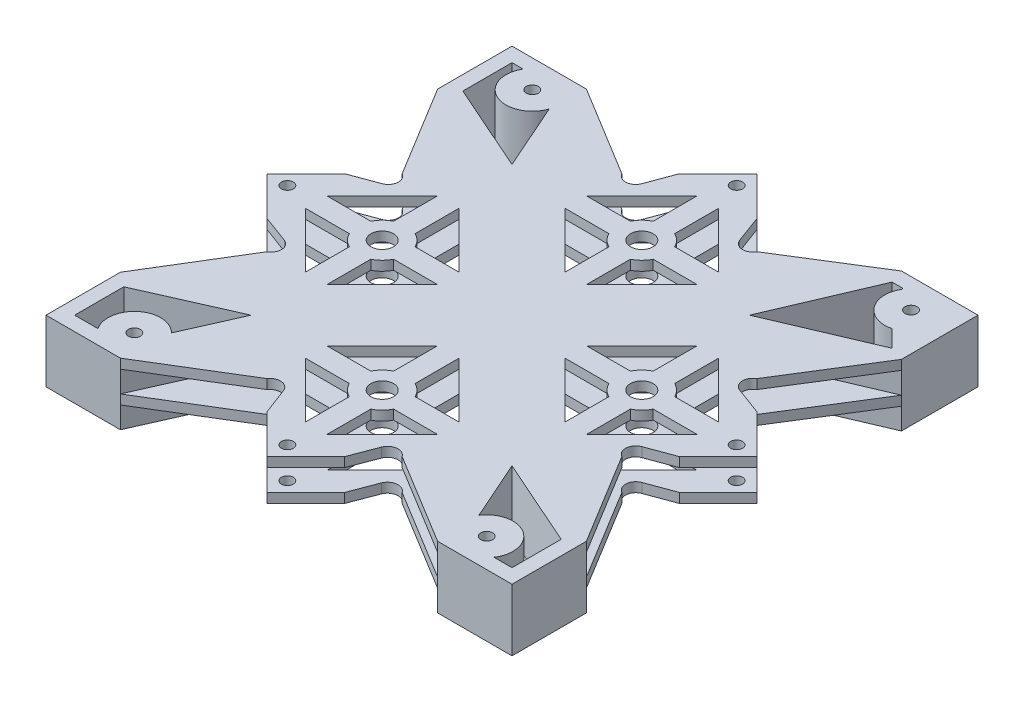
from build123d import *

# Parameters (mm, degrees)
SKETCH1_W            = 97.6
SKETCH1_H            = 97.6
BOSS_EXTRUDE1_DEPTH  = 2
SKETCH3_R            = 1.25
CUT_EXTRUDE1_DEPTH   = 10
FILLET1_R            = 0.2
SKETCH5_R            = 1.25
SKETCH5_R_2          = 1.248424064
SKETCH5_R_3          = 2.375
CUT_EXTRUDE2_DEPTH   = 10
SKETCH6_W            = 104.867444639
SKETCH6_H            = 104.070743389
SKETCH6_W_2          = 97.6
SKETCH6_H_2          = 97.6
BOSS_EXTRUDE2_DEPTH  = 2
SKETCH9_W            = 104.867444639
SKETCH9_H            = 104.070743389
CUT_EXTRUDE3_DEPTH   = 2
SKETCH11_R           = 1.25
BOSS_EXTRUDE3_DEPTH  = 4.5
CUT_EXTRUDE4_DEPTH   = 4.5
BOSS_EXTRUDE4_DEPTH  = 2
SKETCH15_R           = 1.25
SKETCH15_R_2         = 2.375
SKETCH15_R_3         = 1.248424064
CUT_EXTRUDE5_DEPTH   = 9.5
SKETCH16_R           = 1.25
BOSS_EXTRUDE10_DEPTH = 4.5
CUT_EXTRUDE6_DEPTH   = 1.85


with BuildPart() as part:
    # Sketch1 → Boss-Extrude1 (new body)
    with BuildSketch(Plane(origin=(0, 0, 0), x_dir=(1, 0, 0), z_dir=(0, 1, 0))):
        with Locations((48.8, 48.8)):
            Rectangle(SKETCH1_W, SKETCH1_H)
    extrude(amount=BOSS_EXTRUDE1_DEPTH)

    # Sketch3 → Cut-Extrude1 (cut)
    with BuildSketch(Plane.XZ):
        with BuildLine():
            Line((3, -84.3), (3, -94.6))
            Line((3, -94.6), (5.316079849, -94.6))
            ThreePointArc((5.316079849, -94.6), (7.792729855, -86.784550719), (15.285000001, -90.113353923))
            Line((15.285000001, -90.113353923), (21.472818771, -76.127181229))
            Line((21.472818771, -76.127181229), (3, -84.3))
        make_face()
        with BuildLine():
            Line((3, -13.3), (21.472818771, -21.472818771))
            Line((21.472818771, -21.472818771), (16.360495139, -9.917560959))
            ThreePointArc((16.360495139, -9.917560959), (8.975209709, -10.313312378), (7.873156109, -3))
            Line((7.873156109, -3), (3, -3))
            Line((3, -3), (3, -13.3))
        make_face()
        with BuildLine():
            Line((94.6, -13.3), (94.6, -3))
            Line((94.6, -3), (90.826843891, -3))
            ThreePointArc((90.826843891, -3), (89.267333256, -10.648445392), (81.630186258, -9.034513526))
            Line((81.630186258, -9.034513526), (76.127181229, -21.472818771))
            Line((76.127181229, -21.472818771), (94.6, -13.3))
        make_face()
        with BuildLine():
            Line((91.027327292, -86.172672708), (94.6, -82.6))
            Line((94.6, -82.6), (73.674141566, -73.674141566))
            Line((73.674141566, -73.674141566), (82.6, -94.6))
            Line((82.6, -94.6), (85.116873323, -94.6))
            ThreePointArc((85.116873323, -94.6), (85.157069093, -88.341897208), (91.027327292, -86.172672708))
        make_face()
        with Locations((89.66, -91.5)):
            Circle(SKETCH3_R)
        with Locations((10.05, -91.8)):
            Circle(SKETCH3_R)
        with Locations((12.45, -6.05)):
            Circle(SKETCH3_R)
        with Locations((86.25, -6.05)):
            Circle(SKETCH3_R)
    extrude(amount=-CUT_EXTRUDE1_DEPTH, mode=Mode.SUBTRACT)

    # Fillet1
    fillet1_edges = [part.edges().sort_by_distance(p)[0] for p in [
        (85.116873323, 1, -94.6),
    ]]
    fillet(fillet1_edges, radius=FILLET1_R)

    # Sketch5 → Cut-Extrude2 (cut)
    with BuildSketch(Plane.XZ):
        with BuildLine():
            Line((51.05, -80.617052601), (51.05, -89.767052601))
            Line((51.05, -89.767052601), (62.582493929, -78.234558673))
            Line((62.582493929, -78.234558673), (53.432493929, -78.234558673))
            ThreePointArc((53.432493929, -78.234558673), (52.441599923, -79.626158596), (51.05, -80.617052601))
        make_face()
        with BuildLine():
            Line((46.55, -89.767052601), (46.55, -80.617052601))
            ThreePointArc((46.55, -80.617052601), (45.158400077, -79.626158596), (44.167506071, -78.234558673))
            Line((44.167506071, -78.234558673), (35.017506071, -78.234558673))
            Line((35.017506071, -78.234558673), (46.55, -89.767052601))
        make_face()
        with BuildLine():
            Line((35.017506071, -73.734558673), (44.167506071, -73.734558673))
            ThreePointArc((44.167506071, -73.734558673), (45.158400077, -72.34295875), (46.55, -71.352064744))
            Line((46.55, -71.352064744), (46.55, -62.202064744))
            Line((46.55, -62.202064744), (35.017506071, -73.734558673))
        make_face()
        with BuildLine():
            ThreePointArc((51.05, -71.352064744), (52.441599923, -72.34295875), (53.432493929, -73.734558673))
            Line((53.432493929, -73.734558673), (62.582493929, -73.734558673))
            Line((62.582493929, -73.734558673), (51.05, -62.202064744))
            Line((51.05, -62.202064744), (51.05, -71.352064744))
        make_face()
        with BuildLine():
            Line((73.734558673, -35.017506071), (62.202064744, -46.55))
            Line((62.202064744, -46.55), (71.352064744, -46.55))
            ThreePointArc((71.352064744, -46.55), (72.34295875, -45.158400077), (73.734558673, -44.167506071))
            Line((73.734558673, -44.167506071), (73.734558673, -35.017506071))
        make_face()
        with BuildLine():
            ThreePointArc((73.734558673, -53.432493929), (72.34295875, -52.441599923), (71.352064744, -51.05))
            Line((71.352064744, -51.05), (62.202064744, -51.05))
            Line((62.202064744, -51.05), (73.734558673, -62.582493929))
            Line((73.734558673, -62.582493929), (73.734558673, -53.432493929))
        make_face()
        with BuildLine():
            Line((78.234558673, -35.017506071), (78.234558673, -44.167506071))
            ThreePointArc((78.234558673, -44.167506071), (79.626158596, -45.158400077), (80.617052601, -46.55))
            Line((80.617052601, -46.55), (89.767052601, -46.55))
            Line((89.767052601, -46.55), (78.234558673, -35.017506071))
        make_face()
        with BuildLine():
            ThreePointArc((80.617052601, -51.05), (79.626158596, -52.441599923), (78.234558673, -53.432493929))
            Line((78.234558673, -53.432493929), (78.234558673, -62.582493929))
            Line((78.234558673, -62.582493929), (89.767052601, -51.05))
            Line((89.767052601, -51.05), (80.617052601, -51.05))
        make_face()
        with BuildLine():
            Line((46.55, -16.982947399), (46.55, -7.832947399))
            Line((46.55, -7.832947399), (35.017506071, -19.365441327))
            Line((35.017506071, -19.365441327), (44.167506071, -19.365441327))
            ThreePointArc((44.167506071, -19.365441327), (45.158400077, -17.973841404), (46.55, -16.982947399))
        make_face()
        with BuildLine():
            Line((51.05, -7.832947399), (51.05, -16.982947399))
            ThreePointArc((51.05, -16.982947399), (52.441599923, -17.973841404), (53.432493929, -19.365441327))
            Line((53.432493929, -19.365441327), (62.582493929, -19.365441327))
            Line((62.582493929, -19.365441327), (51.05, -7.832947399))
        make_face()
        with BuildLine():
            ThreePointArc((46.55, -26.247935256), (45.158400077, -25.25704125), (44.167506071, -23.865441327))
            Line((44.167506071, -23.865441327), (35.017506071, -23.865441327))
            Line((35.017506071, -23.865441327), (46.55, -35.397935256))
            Line((46.55, -35.397935256), (46.55, -26.247935256))
        make_face()
        with BuildLine():
            Line((62.582493929, -23.865441327), (53.432493929, -23.865441327))
            ThreePointArc((53.432493929, -23.865441327), (52.441599923, -25.25704125), (51.05, -26.247935256))
            Line((51.05, -26.247935256), (51.05, -35.397935256))
            Line((51.05, -35.397935256), (62.582493929, -23.865441327))
        make_face()
        with BuildLine():
            Line((23.865441327, -62.582493929), (35.397935256, -51.05))
            Line((35.397935256, -51.05), (26.247935256, -51.05))
            ThreePointArc((26.247935256, -51.05), (25.25704125, -52.441599923), (23.865441327, -53.432493929))
            Line((23.865441327, -53.432493929), (23.865441327, -62.582493929))
        make_face()
        with BuildLine():
            Line((19.365441327, -62.582493929), (19.365441327, -53.432493929))
            ThreePointArc((19.365441327, -53.432493929), (17.973841404, -52.441599923), (16.982947399, -51.05))
            Line((16.982947399, -51.05), (7.832947399, -51.05))
            Line((7.832947399, -51.05), (19.365441327, -62.582493929))
        make_face()
        with BuildLine():
            ThreePointArc((23.865441327, -44.167506071), (25.25704125, -45.158400077), (26.247935256, -46.55))
            Line((26.247935256, -46.55), (35.397935256, -46.55))
            Line((35.397935256, -46.55), (23.865441327, -35.017506071))
            Line((23.865441327, -35.017506071), (23.865441327, -44.167506071))
        make_face()
        with BuildLine():
            Line((7.832947399, -46.55), (16.982947399, -46.55))
            ThreePointArc((16.982947399, -46.55), (17.973841404, -45.158400077), (19.365441327, -44.167506071))
            Line((19.365441327, -44.167506071), (19.365441327, -35.017506071))
            Line((19.365441327, -35.017506071), (7.832947399, -46.55))
        make_face()
        with Locations((48.8, -95.854595373)):
            Circle(SKETCH5_R)
        with Locations((95.84456992, -48.8)):
            Circle(SKETCH5_R_2)
        with Locations((1.75, -48.8)):
            Circle(SKETCH5_R)
        with Locations((48.8, -1.75)):
            Circle(SKETCH5_R)
        with Locations((48.8, -75.984558673)):
            Circle(SKETCH5_R_3)
        with Locations((75.984558673, -48.8)):
            Circle(SKETCH5_R_3)
        with Locations((48.8, -21.615441327)):
            Circle(SKETCH5_R_3)
        with Locations((21.615441327, -48.8)):
            Circle(SKETCH5_R_3)
    extrude(amount=-CUT_EXTRUDE2_DEPTH, mode=Mode.SUBTRACT)

    # Sketch6 → Boss-Extrude2 (add)
    with BuildSketch(Plane(origin=(0, 2, 0), x_dir=(1, 0, 0), z_dir=(0, 1, 0))):
        with Locations((49.842483603, 49.323375799)):
            Rectangle(SKETCH6_W, SKETCH6_H)
        with Locations((48.8, 48.8)):
            Rectangle(SKETCH6_W_2, SKETCH6_H_2, mode=Mode.SUBTRACT)
    extrude(amount=-BOSS_EXTRUDE2_DEPTH)

    # Sketch9 → Cut-Extrude3 (cut)
    with BuildSketch(Plane(origin=(0, 2, 0), x_dir=(1, 0, 0), z_dir=(0, 1, 0))):
        with Locations((49.842483603, 49.323375799)):
            Rectangle(SKETCH9_W, SKETCH9_H)
        Polygon((81.575043976, 97.6), (97.6, 97.6), (97.6, 81.575043976), (97.6, 51.29456992), (100.09456992, 48.8), (97.6, 46.30543008), (97.6, 15.581273054), (97.6, 0), (82.018726946, 0), (51.29456992, 0), (48.8, -2.49456992), (46.30543008, 0), (15.581273054, 0), (0, 0), (0, 15.581273054), (0, 46.30543008), (-2.49456992, 48.8), (0, 51.29456992), (0, 82.018726946), (0, 97.6), (15.581273054, 97.6), (46.30543008, 97.6), (48.8, 100.09456992), (51.29456992, 97.6), align=None, mode=Mode.SUBTRACT)
        with BuildLine():
            Line((40.668272016, 91.962841937), (46.30543008, 97.6))
            Line((46.30543008, 97.6), (15.581273054, 97.6))
            Line((15.581273054, 97.6), (34.657864376, 85.952434296))
            ThreePointArc((34.657864376, 85.952434296), (36.694771141, 84.840299118), (38.55, 86.234558673))
            Line((38.55, 86.234558673), (40.668272016, 91.962841937))
        make_face()
        with BuildLine():
            Line((62.942135624, 85.952434296), (81.575043976, 97.6))
            Line((81.575043976, 97.6), (51.29456992, 97.6))
            Line((51.29456992, 97.6), (56.931727984, 91.962841937))
            Line((56.931727984, 91.962841937), (59.05, 86.234558673))
            ThreePointArc((59.05, 86.234558673), (60.905228859, 84.840299118), (62.942135624, 85.952434296))
        make_face()
        with BuildLine():
            Line((97.6, 51.29456992), (97.6, 81.575043976))
            Line((97.6, 81.575043976), (85.952434296, 62.942135624))
            ThreePointArc((85.952434296, 62.942135624), (84.840299118, 60.905228859), (86.234558673, 59.05))
            Line((86.234558673, 59.05), (91.962841937, 56.931727984))
            Line((91.962841937, 56.931727984), (97.6, 51.29456992))
        make_face()
        with BuildLine():
            Line((97.6, 15.581273054), (97.6, 46.30543008))
            Line((97.6, 46.30543008), (91.962841937, 40.668272016))
            Line((91.962841937, 40.668272016), (86.234558673, 38.55))
            ThreePointArc((86.234558673, 38.55), (84.840299118, 36.694771141), (85.952434296, 34.657864376))
            Line((85.952434296, 34.657864376), (97.6, 15.581273054))
        make_face()
        with BuildLine():
            Line((51.29456992, 0), (82.018726946, 0))
            Line((82.018726946, 0), (62.942135624, 11.647565704))
            ThreePointArc((62.942135624, 11.647565704), (60.858639354, 12.601902927), (59.05, 11.194586358))
            Line((59.05, 11.194586358), (56.931727984, 5.637158063))
            Line((56.931727984, 5.637158063), (51.29456992, 0))
        make_face()
        with BuildLine():
            Line((15.581273054, 0), (46.30543008, 0))
            Line((46.30543008, 0), (40.668272016, 5.637158063))
            Line((40.668272016, 5.637158063), (38.55, 11.194586358))
            ThreePointArc((38.55, 11.194586358), (36.741360646, 12.601902927), (34.657864376, 11.647565704))
            Line((34.657864376, 11.647565704), (15.581273054, 0))
        make_face()
        with BuildLine():
            Line((5.637158063, 40.668272016), (0, 46.30543008))
            Line((0, 46.30543008), (0, 15.581273054))
            Line((0, 15.581273054), (11.647565704, 34.657864376))
            ThreePointArc((11.647565704, 34.657864376), (12.759700882, 36.694771141), (11.365441327, 38.55))
            Line((11.365441327, 38.55), (5.637158063, 40.668272016))
        make_face()
        with BuildLine():
            Line((11.647565704, 62.942135624), (0, 82.018726946))
            Line((0, 82.018726946), (0, 51.29456992))
            Line((0, 51.29456992), (5.637158063, 56.931727984))
            Line((5.637158063, 56.931727984), (11.365441327, 59.05))
            ThreePointArc((11.365441327, 59.05), (12.759700882, 60.905228859), (11.647565704, 62.942135624))
        make_face()
    extrude(amount=-CUT_EXTRUDE3_DEPTH, mode=Mode.SUBTRACT)

    # Sketch11 → Boss-Extrude3 (add)
    with BuildSketch(Plane.XZ):
        Polygon((97.6, -97.6), (81.575043976, -97.6), (69.655336569, -69.655336569), (97.6, -81.575043976), align=None)
        with Locations((89.66, -91.5)):
            Circle(SKETCH11_R, mode=Mode.SUBTRACT)
        with BuildLine():
            ThreePointArc((84.752862341, -94.6), (84.926573132, -94.499118926), (84.92504261, -94.298245614))
            ThreePointArc((84.92504261, -94.298245614), (85.26210654, -88.197193145), (91.027327292, -86.172672708))
            Line((91.027327292, -86.172672708), (94.6, -82.6))
            Line((94.6, -82.6), (73.674141566, -73.674141566))
            Line((73.674141566, -73.674141566), (82.6, -94.6))
            Line((82.6, -94.6), (84.752862341, -94.6))
        make_face(mode=Mode.SUBTRACT)
        Polygon((48.8, -49.789949494), (47.810050506, -48.8), (26.169211238, -70.440839268), (27.944663431, -69.655336569), (27.159160732, -71.430788762), align=None)
        Polygon((71.430788762, -27.159160732), (69.655336569, -27.944663431), (70.440839268, -26.169211238), (48.8, -47.810050506), (49.789949494, -48.8), align=None)
        Polygon((47.810050506, -48.8), (48.8, -47.810050506), (27.159160732, -26.169211238), (27.944663431, -27.944663431), (26.169211238, -27.159160732), align=None)
        Polygon((71.381631816, -70.391682322), (49.789949494, -48.8), (48.8, -49.789949494), (70.391682322, -71.381631816), (69.655336569, -69.655336569), align=None)
        Polygon((49.789949494, -48.8), (48.8, -47.810050506), (47.810050506, -48.8), (48.8, -49.789949494), align=None)
        Polygon((15.581273054, -97.6), (0, -97.6), (0, -82.018726946), (27.944663431, -69.655336569), align=None)
        with Locations((10.05, -91.8)):
            Circle(SKETCH11_R, mode=Mode.SUBTRACT)
        with BuildLine():
            Line((21.472818771, -76.127181229), (15.285000001, -90.113353923))
            ThreePointArc((15.285000001, -90.113353923), (7.792729855, -86.784550719), (5.316079849, -94.6))
            Line((5.316079849, -94.6), (3, -94.6))
            Line((3, -94.6), (3, -84.3))
            Line((3, -84.3), (21.472818771, -76.127181229))
        make_face(mode=Mode.SUBTRACT)
        Polygon((0, 0), (15.581273054, 0), (27.944663431, -27.944663431), (0, -15.581273054), align=None)
        with Locations((12.45, -6.05)):
            Circle(SKETCH11_R, mode=Mode.SUBTRACT)
        with BuildLine():
            Line((3, -3), (7.873156109, -3))
            ThreePointArc((7.873156109, -3), (8.975209709, -10.313312378), (16.360495139, -9.917560959))
            Line((16.360495139, -9.917560959), (21.472818771, -21.472818771))
            Line((21.472818771, -21.472818771), (3, -13.3))
            Line((3, -13.3), (3, -3))
        make_face(mode=Mode.SUBTRACT)
        Polygon((82.018726946, 0), (97.6, 0), (97.6, -15.581273054), (69.655336569, -27.944663431), align=None)
        with Locations((86.25, -6.05)):
            Circle(SKETCH11_R, mode=Mode.SUBTRACT)
        with BuildLine():
            Line((76.127181229, -21.472818771), (81.630186258, -9.034513526))
            ThreePointArc((81.630186258, -9.034513526), (89.267333256, -10.648445392), (90.826843891, -3))
            Line((90.826843891, -3), (94.6, -3))
            Line((94.6, -3), (94.6, -13.3))
            Line((94.6, -13.3), (76.127181229, -21.472818771))
        make_face(mode=Mode.SUBTRACT)
    extrude(amount=BOSS_EXTRUDE3_DEPTH)

    # Sketch12 → Cut-Extrude4 (cut)
    with BuildSketch(Plane.XZ.offset(4.5)):
        Polygon((26.876318019, -71.14794605), (71.148273589, -26.875990479), (70.724009521, -26.451726411), (26.45205395, -70.723681981), align=None)
        Polygon((26.45205395, -26.876318019), (70.724009521, -71.148273589), (71.148273589, -70.724009521), (26.876318019, -26.45205395), align=None)
    extrude(amount=-CUT_EXTRUDE4_DEPTH, mode=Mode.SUBTRACT)

    # Sketch13 → Boss-Extrude4 (add)
    with BuildSketch(Plane.XZ.offset(4.5)):
        with BuildLine():
            Line((0, -82.018726946), (0, -97.6))
            Line((0, -97.6), (15.581273054, -97.6))
            Line((15.581273054, -97.6), (34.657864376, -85.952434296))
            ThreePointArc((34.657864376, -85.952434296), (36.694771141, -84.840299118), (38.55, -86.234558673))
            Line((38.55, -86.234558673), (40.668272016, -91.962841937))
            Line((40.668272016, -91.962841937), (48.8, -100.09456992))
            Line((48.8, -100.09456992), (56.931727984, -91.962841937))
            Line((56.931727984, -91.962841937), (59.05, -86.234558673))
            ThreePointArc((59.05, -86.234558673), (60.905228859, -84.840299118), (62.942135624, -85.952434296))
            Line((62.942135624, -85.952434296), (81.575043976, -97.6))
            Line((81.575043976, -97.6), (97.6, -97.6))
            Line((97.6, -97.6), (97.6, -81.575043976))
            Line((97.6, -81.575043976), (85.952434296, -62.942135624))
            ThreePointArc((85.952434296, -62.942135624), (84.840299118, -60.905228859), (86.234558673, -59.05))
            Line((86.234558673, -59.05), (91.962841937, -56.931727984))
            Line((91.962841937, -56.931727984), (100.09456992, -48.8))
            Line((100.09456992, -48.8), (91.962841937, -40.668272016))
            Line((91.962841937, -40.668272016), (86.234558673, -38.55))
            ThreePointArc((86.234558673, -38.55), (84.840299118, -36.694771141), (85.952434296, -34.657864376))
            Line((85.952434296, -34.657864376), (97.6, -15.581273054))
            Line((97.6, -15.581273054), (97.6, 0))
            Line((97.6, 0), (82.018726946, 0))
            Line((82.018726946, 0), (62.942135624, -11.647565704))
            ThreePointArc((62.942135624, -11.647565704), (60.858639354, -12.601902927), (59.05, -11.194586358))
            Line((59.05, -11.194586358), (56.931727984, -5.637158063))
            Line((56.931727984, -5.637158063), (48.8, 2.49456992))
            Line((48.8, 2.49456992), (40.668272016, -5.637158063))
            Line((40.668272016, -5.637158063), (38.55, -11.194586358))
            ThreePointArc((38.55, -11.194586358), (36.741360646, -12.601902927), (34.657864376, -11.647565704))
            Line((34.657864376, -11.647565704), (15.581273054, 0))
            Line((15.581273054, 0), (0, 0))
            Line((0, 0), (0, -15.581273054))
            Line((0, -15.581273054), (11.647565704, -34.657864376))
            ThreePointArc((11.647565704, -34.657864376), (12.759700882, -36.694771141), (11.365441327, -38.55))
            Line((11.365441327, -38.55), (5.637158063, -40.668272016))
            Line((5.637158063, -40.668272016), (-2.49456992, -48.8))
            Line((-2.49456992, -48.8), (5.637158063, -56.931727984))
            Line((5.637158063, -56.931727984), (11.365441327, -59.05))
            ThreePointArc((11.365441327, -59.05), (12.759700882, -60.905228859), (11.647565704, -62.942135624))
            Line((11.647565704, -62.942135624), (0, -82.018726946))
        make_face()
    extrude(amount=BOSS_EXTRUDE4_DEPTH)

    # Sketch15 → Cut-Extrude5 (cut, through all)
    with BuildSketch(Plane.XZ.offset(6.5)):
        with BuildLine():
            ThreePointArc((53.432493929, -73.734558673), (52.441599923, -72.34295875), (51.05, -71.352064744))
            Line((51.05, -71.352064744), (51.05, -62.202064744))
            Line((51.05, -62.202064744), (62.582493929, -73.734558673))
            Line((62.582493929, -73.734558673), (53.432493929, -73.734558673))
        make_face()
        with BuildLine():
            ThreePointArc((51.05, -80.617052601), (52.441599923, -79.626158596), (53.432493929, -78.234558673))
            Line((53.432493929, -78.234558673), (62.582493929, -78.234558673))
            Line((62.582493929, -78.234558673), (51.05, -89.767052601))
            Line((51.05, -89.767052601), (51.05, -80.617052601))
        make_face()
        with BuildLine():
            ThreePointArc((44.167506071, -78.234558673), (45.158400077, -79.626158596), (46.55, -80.617052601))
            Line((46.55, -80.617052601), (46.55, -89.767052601))
            Line((46.55, -89.767052601), (35.017506071, -78.234558673))
            Line((35.017506071, -78.234558673), (44.167506071, -78.234558673))
        make_face()
        with BuildLine():
            ThreePointArc((46.55, -71.352064744), (45.158400077, -72.34295875), (44.167506071, -73.734558673))
            Line((44.167506071, -73.734558673), (35.017506071, -73.734558673))
            Line((35.017506071, -73.734558673), (46.55, -62.202064744))
            Line((46.55, -62.202064744), (46.55, -71.352064744))
        make_face()
        with BuildLine():
            ThreePointArc((15.285000001, -90.113353923), (7.792729855, -86.784550719), (5.316079849, -94.6))
            Line((5.316079849, -94.6), (3, -94.6))
            Line((3, -94.6), (3, -84.3))
            Line((3, -84.3), (21.472818771, -76.127181229))
            Line((21.472818771, -76.127181229), (15.285000001, -90.113353923))
        make_face()
        with Locations((10.05, -91.8)):
            Circle(SKETCH15_R)
        with BuildLine():
            ThreePointArc((16.982947399, -51.05), (17.973841404, -52.441599923), (19.365441327, -53.432493929))
            Line((19.365441327, -53.432493929), (19.365441327, -62.582493929))
            Line((19.365441327, -62.582493929), (7.832947399, -51.05))
            Line((7.832947399, -51.05), (16.982947399, -51.05))
        make_face()
        with BuildLine():
            ThreePointArc((19.365441327, -44.167506071), (17.973841404, -45.158400077), (16.982947399, -46.55))
            Line((16.982947399, -46.55), (7.832947399, -46.55))
            Line((7.832947399, -46.55), (19.365441327, -35.017506071))
            Line((19.365441327, -35.017506071), (19.365441327, -44.167506071))
        make_face()
        with BuildLine():
            ThreePointArc((26.247935256, -46.55), (25.25704125, -45.158400077), (23.865441327, -44.167506071))
            Line((23.865441327, -44.167506071), (23.865441327, -35.017506071))
            Line((23.865441327, -35.017506071), (35.397935256, -46.55))
            Line((35.397935256, -46.55), (26.247935256, -46.55))
        make_face()
        with BuildLine():
            ThreePointArc((23.865441327, -53.432493929), (25.25704125, -52.441599923), (26.247935256, -51.05))
            Line((26.247935256, -51.05), (35.397935256, -51.05))
            Line((35.397935256, -51.05), (23.865441327, -62.582493929))
            Line((23.865441327, -62.582493929), (23.865441327, -53.432493929))
        make_face()
        with Locations((21.615441327, -48.8)):
            Circle(SKETCH15_R_2)
        with Locations((1.75, -48.8)):
            Circle(SKETCH15_R)
        with BuildLine():
            ThreePointArc((7.873156109, -3), (8.975209709, -10.313312378), (16.360495139, -9.917560959))
            Line((16.360495139, -9.917560959), (21.472818771, -21.472818771))
            Line((21.472818771, -21.472818771), (3, -13.3))
            Line((3, -13.3), (3, -3))
            Line((3, -3), (7.873156109, -3))
        make_face()
        with Locations((12.45, -6.05)):
            Circle(SKETCH15_R)
        with BuildLine():
            ThreePointArc((71.352064744, -51.05), (72.34295875, -52.441599923), (73.734558673, -53.432493929))
            Line((73.734558673, -53.432493929), (73.734558673, -62.582493929))
            Line((73.734558673, -62.582493929), (62.202064744, -51.05))
            Line((62.202064744, -51.05), (71.352064744, -51.05))
        make_face()
        with BuildLine():
            ThreePointArc((78.234558673, -53.432493929), (79.626158596, -52.441599923), (80.617052601, -51.05))
            Line((80.617052601, -51.05), (89.767052601, -51.05))
            Line((89.767052601, -51.05), (78.234558673, -62.582493929))
            Line((78.234558673, -62.582493929), (78.234558673, -53.432493929))
        make_face()
        with BuildLine():
            ThreePointArc((73.734558673, -44.167506071), (72.34295875, -45.158400077), (71.352064744, -46.55))
            Line((71.352064744, -46.55), (62.202064744, -46.55))
            Line((62.202064744, -46.55), (73.734558673, -35.017506071))
            Line((73.734558673, -35.017506071), (73.734558673, -44.167506071))
        make_face()
        with BuildLine():
            ThreePointArc((80.617052601, -46.55), (79.626158596, -45.158400077), (78.234558673, -44.167506071))
            Line((78.234558673, -44.167506071), (78.234558673, -35.017506071))
            Line((78.234558673, -35.017506071), (89.767052601, -46.55))
            Line((89.767052601, -46.55), (80.617052601, -46.55))
        make_face()
        with Locations((89.66, -91.5)):
            Circle(SKETCH15_R)
        with BuildLine():
            ThreePointArc((81.630186258, -9.034513526), (89.267333256, -10.648445392), (90.826843891, -3))
            Line((90.826843891, -3), (94.6, -3))
            Line((94.6, -3), (94.6, -13.3))
            Line((94.6, -13.3), (76.127181229, -21.472818771))
            Line((76.127181229, -21.472818771), (81.630186258, -9.034513526))
        make_face()
        with BuildLine():
            ThreePointArc((51.05, -26.247935256), (52.441599923, -25.25704125), (53.432493929, -23.865441327))
            Line((53.432493929, -23.865441327), (62.582493929, -23.865441327))
            Line((62.582493929, -23.865441327), (51.05, -35.397935256))
            Line((51.05, -35.397935256), (51.05, -26.247935256))
        make_face()
        with BuildLine():
            ThreePointArc((53.432493929, -19.365441327), (52.441599923, -17.973841404), (51.05, -16.982947399))
            Line((51.05, -16.982947399), (51.05, -7.832947399))
            Line((51.05, -7.832947399), (62.582493929, -19.365441327))
            Line((62.582493929, -19.365441327), (53.432493929, -19.365441327))
        make_face()
        with BuildLine():
            ThreePointArc((44.167506071, -23.865441327), (45.158400077, -25.25704125), (46.55, -26.247935256))
            Line((46.55, -26.247935256), (46.55, -35.397935256))
            Line((46.55, -35.397935256), (35.017506071, -23.865441327))
            Line((35.017506071, -23.865441327), (44.167506071, -23.865441327))
        make_face()
        with BuildLine():
            ThreePointArc((46.55, -16.982947399), (45.158400077, -17.973841404), (44.167506071, -19.365441327))
            Line((44.167506071, -19.365441327), (35.017506071, -19.365441327))
            Line((35.017506071, -19.365441327), (46.55, -7.832947399))
            Line((46.55, -7.832947399), (46.55, -16.982947399))
        make_face()
        with Locations((48.8, -21.615441327)):
            Circle(SKETCH15_R_2)
        with Locations((48.8, -75.984558673)):
            Circle(SKETCH15_R_2)
        with Locations((48.8, -95.854595373)):
            Circle(SKETCH15_R)
        with Locations((95.84456992, -48.8)):
            Circle(SKETCH15_R_3)
        with Locations((48.8, -1.75)):
            Circle(SKETCH15_R)
        with Locations((75.984558673, -48.8)):
            Circle(SKETCH15_R_2)
        with Locations((86.25, -6.05)):
            Circle(SKETCH15_R)
        with BuildLine():
            Line((82.6, -94.6), (84.752862341, -94.6))
            ThreePointArc((84.752862341, -94.6), (84.926573132, -94.499118926), (84.92504261, -94.298245614))
            ThreePointArc((84.92504261, -94.298245614), (85.26210654, -88.197193145), (91.027327292, -86.172672708))
            Line((91.027327292, -86.172672708), (94.6, -82.6))
            Line((94.6, -82.6), (73.674141566, -73.674141566))
            Line((73.674141566, -73.674141566), (82.6, -94.6))
        make_face()
    extrude(amount=-CUT_EXTRUDE5_DEPTH, mode=Mode.SUBTRACT)

    # Sketch16 → Boss-Extrude10 (add)
    with BuildSketch(Plane.XZ.offset(6.5)):
        Polygon((0, 0), (0, -15.581273054), (26.169211238, -27.159160732), (47.810050506, -48.8), (26.169211238, -70.440839268), (0, -82.018726946), (0, -97.6), (15.581273054, -97.6), (27.159160732, -71.430788762), (48.8, -49.789949494), (70.391682322, -71.381631816), (81.575043976, -97.6), (97.6, -97.6), (97.6, -81.575043976), (71.381631816, -70.391682322), (49.789949494, -48.8), (71.430788762, -27.159160732), (97.6, -15.581273054), (97.6, 0), (82.018726946, 0), (70.440839268, -26.169211238), (48.8, -47.810050506), (27.159160732, -26.169211238), (15.581273054, 0), align=None)
        with BuildLine():
            Line((21.472818771, -21.472818771), (3, -13.3))
            Line((3, -13.3), (3, -3))
            Line((3, -3), (7.873156109, -3))
            ThreePointArc((7.873156109, -3), (8.975209709, -10.313312378), (16.360495139, -9.917560959))
            Line((16.360495139, -9.917560959), (21.472818771, -21.472818771))
        make_face(mode=Mode.SUBTRACT)
        with Locations((12.45, -6.05)):
            Circle(SKETCH16_R, mode=Mode.SUBTRACT)
        with BuildLine():
            Line((21.472818771, -76.127181229), (15.285000001, -90.113353923))
            ThreePointArc((15.285000001, -90.113353923), (7.792729855, -86.784550719), (5.316079849, -94.6))
            Line((5.316079849, -94.6), (3, -94.6))
            Line((3, -94.6), (3, -84.3))
            Line((3, -84.3), (21.472818771, -76.127181229))
        make_face(mode=Mode.SUBTRACT)
        with Locations((10.05, -91.8)):
            Circle(SKETCH16_R, mode=Mode.SUBTRACT)
        with BuildLine():
            Line((94.6, -82.6), (91.027327292, -86.172672708))
            ThreePointArc((91.027327292, -86.172672708), (85.26210654, -88.197193145), (84.92504261, -94.298245614))
            ThreePointArc((84.92504261, -94.298245614), (84.926573132, -94.499118926), (84.752862341, -94.6))
            Line((84.752862341, -94.6), (82.6, -94.6))
            Line((82.6, -94.6), (73.674141566, -73.674141566))
            Line((73.674141566, -73.674141566), (94.6, -82.6))
        make_face(mode=Mode.SUBTRACT)
        with Locations((89.66, -91.5)):
            Circle(SKETCH16_R, mode=Mode.SUBTRACT)
        with Locations((86.25, -6.05)):
            Circle(SKETCH16_R, mode=Mode.SUBTRACT)
        with BuildLine():
            Line((76.127181229, -21.472818771), (81.630186258, -9.034513526))
            ThreePointArc((81.630186258, -9.034513526), (89.267333256, -10.648445392), (90.826843891, -3))
            Line((90.826843891, -3), (94.6, -3))
            Line((94.6, -3), (94.6, -13.3))
            Line((94.6, -13.3), (76.127181229, -21.472818771))
        make_face(mode=Mode.SUBTRACT)
    extrude(amount=BOSS_EXTRUDE10_DEPTH)

    # Sketch17 → Cut-Extrude6 (cut)
    with BuildSketch(Plane.XZ.offset(11)):
        Polygon((26.45205395, -70.723681981), (26.876318019, -71.14794605), (48.8, -49.224264069), (48.375735931, -48.8), align=None)
        Polygon((26.45205395, -26.876318019), (48.375735931, -48.8), (48.8, -48.375735931), (26.876318019, -26.45205395), align=None)
        Polygon((48.8, -48.375735931), (49.224264069, -48.8), (71.148273589, -26.875990479), (70.724009521, -26.451726411), align=None)
        Polygon((48.375735931, -48.8), (48.8, -49.224264069), (49.224264069, -48.8), (48.8, -48.375735931), align=None)
        Polygon((49.224264069, -48.8), (48.8, -49.224264069), (70.724009521, -71.148273589), (71.148273589, -70.724009521), align=None)
    extrude(amount=-CUT_EXTRUDE6_DEPTH, mode=Mode.SUBTRACT)


solid = part.part
